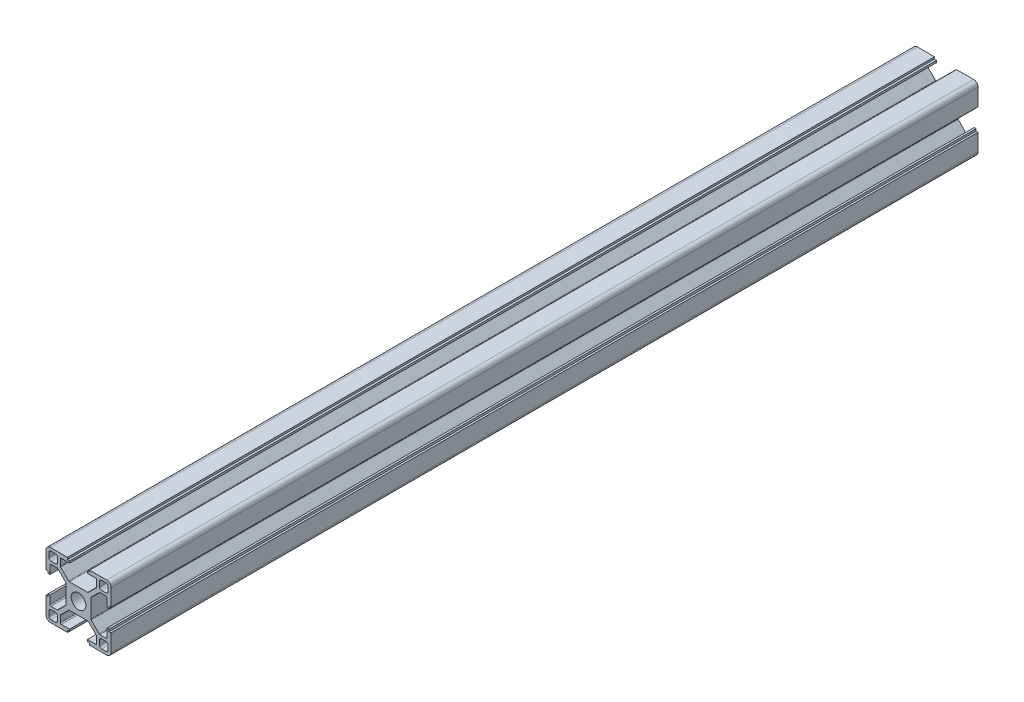
from build123d import *

# Parameters (mm, degrees)
SKETCH_1_W                       = 4
SKETCH_1_H                       = 4
EXTRUDE_1_DEPTH                  = 400
FILLET_1_R                       = 1
FILLET_2_R                       = 2
FILLET_3_R                       = 0.5
PATTERN_CIRCULAR_1_COUNT         = 4
FILLET_1_OF_PATTERN_CIRCULAR_1_R = 1
FILLET_2_OF_PATTERN_CIRCULAR_1_R = 2
FILLET_3_OF_PATTERN_CIRCULAR_1_R = 0.5
SKETCH_2_R                       = 3.4
CUT_EXTRUDE_1_DEPTH              = 401
SKETCH_3_R                       = 3.25
CUT_EXTRUDE_2_DEPTH              = 10


with BuildPart() as part:
    # 草图1 → 凸台-拉伸1 (new body)
    with BuildSketch(Plane.XY):
        Polygon((5.7, 0), (5.7, 4.427207794), (9.672792206, 8.4), (13.2, 8.4), (13.2, 4.1), (14.1, 4.1), (14.1, 5.1), (15, 5.1), (15, 15), (5.1, 15), (5.1, 14.1), (4.1, 14.1), (4.1, 13.2), (8.4, 13.2), (8.4, 9.672792206), (4.427207794, 5.7), (0, 5.7), (0, 0), align=None)
        with Locations((11.7, 11.7)):
            Rectangle(SKETCH_1_W, SKETCH_1_H, mode=Mode.SUBTRACT)
    extrude_1 = extrude(amount=EXTRUDE_1_DEPTH)

    # 圆角1
    fillet_1_edges = [part.edges().sort_by_distance(p)[0] for p in [
        (13.7, 9.7, 200),
        (13.7, 13.7, 200),
        (9.7, 13.7, 200),
        (9.7, 9.7, 200),
    ]]
    fillet(fillet_1_edges, radius=FILLET_1_R)

    # 圆角2
    fillet_2_edges = [part.edges().sort_by_distance(p)[0] for p in [
        (15, 15, 200),
    ]]
    fillet(fillet_2_edges, radius=FILLET_2_R)

    # 圆角3
    fillet_3_edges = [part.edges().sort_by_distance(p)[0] for p in [
        (4.427207794, 5.7, 200),
        (8.4, 9.672792206, 200),
        (8.4, 13.2, 200),
        (13.2, 8.4, 200),
        (9.672792206, 8.4, 200),
        (5.7, 4.427207794, 200),
    ]]
    fillet(fillet_3_edges, radius=FILLET_3_R)

    # 阵列(圆周)1: 凸台-拉伸1 ×4 about axis
    pattern_circular_1_axis = Axis((0, 0, 0), (0, 0, 1))
    for i in range(1, PATTERN_CIRCULAR_1_COUNT):
        add(extrude_1.rotate(pattern_circular_1_axis, i * 360 / PATTERN_CIRCULAR_1_COUNT))

    # 圆角1 of 阵列(圆周)1
    fillet_1_of_pattern_circular_1_edges = [part.edges().sort_by_distance(p)[0] for p in [
        (-9.7, 13.7, 200),
        (-13.7, 13.7, 200),
        (-13.7, 9.7, 200),
        (-9.7, 9.7, 200),
        (-13.7, -9.7, 200),
        (-13.7, -13.7, 200),
        (-9.7, -13.7, 200),
        (-9.7, -9.7, 200),
        (9.7, -13.7, 200),
        (13.7, -13.7, 200),
        (13.7, -9.7, 200),
        (9.7, -9.7, 200),
    ]]
    fillet(fillet_1_of_pattern_circular_1_edges, radius=FILLET_1_OF_PATTERN_CIRCULAR_1_R)

    # 圆角2 of 阵列(圆周)1
    fillet_2_of_pattern_circular_1_edges = [part.edges().sort_by_distance(p)[0] for p in [
        (-15, 15, 200),
        (-15, -15, 200),
        (15, -15, 200),
    ]]
    fillet(fillet_2_of_pattern_circular_1_edges, radius=FILLET_2_OF_PATTERN_CIRCULAR_1_R)

    # 圆角3 of 阵列(圆周)1
    fillet_3_of_pattern_circular_1_edges = [part.edges().sort_by_distance(p)[0] for p in [
        (-5.7, 4.427207794, 200),
        (-9.672792206, 8.4, 200),
        (-13.2, 8.4, 200),
        (-8.4, 13.2, 200),
        (-8.4, 9.672792206, 200),
        (-4.427207794, 5.7, 200),
        (-4.427207794, -5.7, 200),
        (-8.4, -9.672792206, 200),
        (-8.4, -13.2, 200),
        (-13.2, -8.4, 200),
        (-9.672792206, -8.4, 200),
        (-5.7, -4.427207794, 200),
        (5.7, -4.427207794, 200),
        (9.672792206, -8.4, 200),
        (13.2, -8.4, 200),
        (8.4, -13.2, 200),
        (8.4, -9.672792206, 200),
        (4.427207794, -5.7, 200),
    ]]
    fillet(fillet_3_of_pattern_circular_1_edges, radius=FILLET_3_OF_PATTERN_CIRCULAR_1_R)

    # 草图2 → 切除-拉伸1 (cut, through all)
    with BuildSketch(Plane.XY.offset(400)):
        Circle(SKETCH_2_R)
    extrude(amount=-CUT_EXTRUDE_1_DEPTH, mode=Mode.SUBTRACT)

    # 草图3 → 切除-拉伸2 (cut, symmetric)
    with BuildSketch(Plane(origin=(0, 0, 0), x_dir=(1, 0, 0), z_dir=(0, 1, 0))):
        with Locations((0, -50)):
            Circle(SKETCH_3_R)
        with Locations((0, -350)):
            Circle(SKETCH_3_R)
    extrude(amount=CUT_EXTRUDE_2_DEPTH, both=True, mode=Mode.SUBTRACT)


solid = part.part
